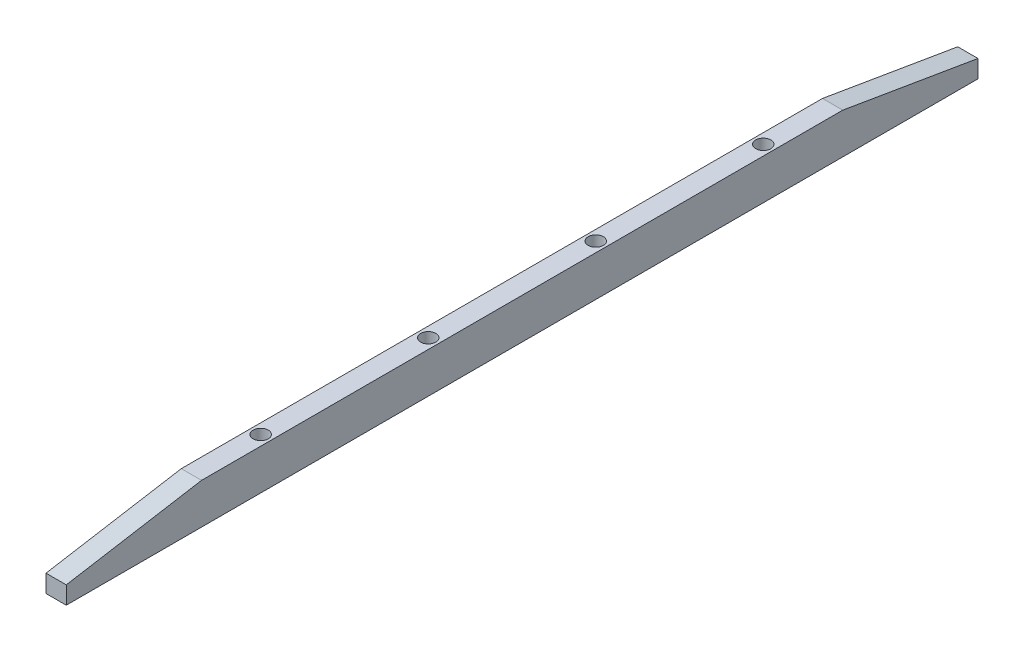
from build123d import *

# Parameters (mm, degrees)
BOSS_EXTRUDE2_DEPTH = 6.35
SKETCH8_R           = 2.38125
CUT_EXTRUDE3_DEPTH  = 12.7


with BuildPart() as part:
    # Sketch7 → Boss-Extrude2 (new body)
    with BuildSketch(Plane(origin=(0, 0, 0), x_dir=(0, 0, -1), z_dir=(1, 0, 0))):
        Polygon((211.186, 0), (0, 0), (-37.279, 0), (-37.279, 5.533348483), (5.116676416, 12.7), (206.069323584, 12.7), (248.465, 5.533348483), (248.465, 0), align=None)
    extrude(amount=BOSS_EXTRUDE2_DEPTH)

    # Sketch8 → Cut-Extrude3 (cut)
    with BuildSketch(Plane.XZ):
        with Locations((3.175, -26.843)):
            Circle(SKETCH8_R)
        with Locations((3.175, -79.343)):
            Circle(SKETCH8_R)
        with Locations((3.175, -131.843)):
            Circle(SKETCH8_R)
        with Locations((3.175, -184.343)):
            Circle(SKETCH8_R)
    extrude(amount=-CUT_EXTRUDE3_DEPTH, mode=Mode.SUBTRACT)


solid = part.part
